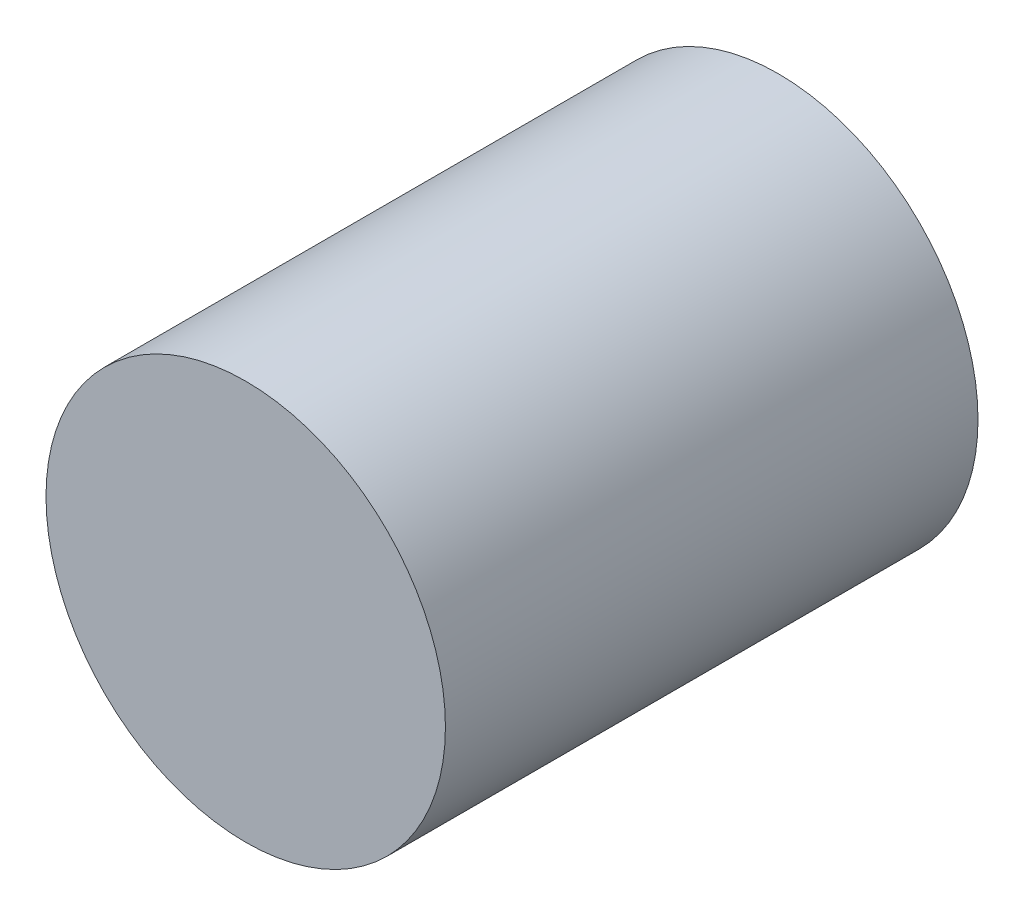
from build123d import *

# Parameters (mm, degrees)
ESQUISSE1_R        = 37.5
BOSS_EXTRU_1_DEPTH = 100


with BuildPart() as part:
    # Esquisse1 → Boss.-Extru.1 (new body)
    with BuildSketch(Plane.XY):
        Circle(ESQUISSE1_R)
    extrude(amount=BOSS_EXTRU_1_DEPTH)


solid = part.part
